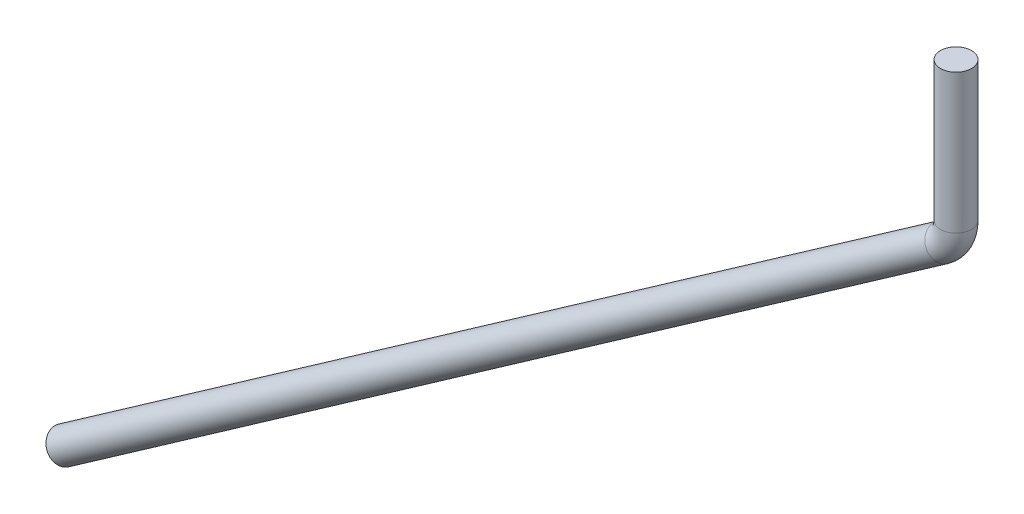
from build123d import *

# Parameters (mm, degrees)
SWEEP1_PROFILE_R = 0.127


with BuildPart() as part:
    # Sweep1: sweep along a path in Sketch1
    with BuildLine(Plane.XY) as sweep1_path:
        Line((0, 0), (0, -1.137775969))
        ThreePointArc((0, -1.137775969), (-0.028699248, -1.255060117), (-0.108311585, -1.345840588))
        Line((-0.108311585, -1.345840588), (-7.282261674, -6.369094519))
    # Sweep1 profile (on start of the path) → Sweep1 (sweep)
    with BuildSketch(Plane(origin=(0, 0, 0), x_dir=(-1, 0, 0), z_dir=(0, -1, 0))):
        Circle(SWEEP1_PROFILE_R)
    sweep(path=sweep1_path.line)


solid = part.part
